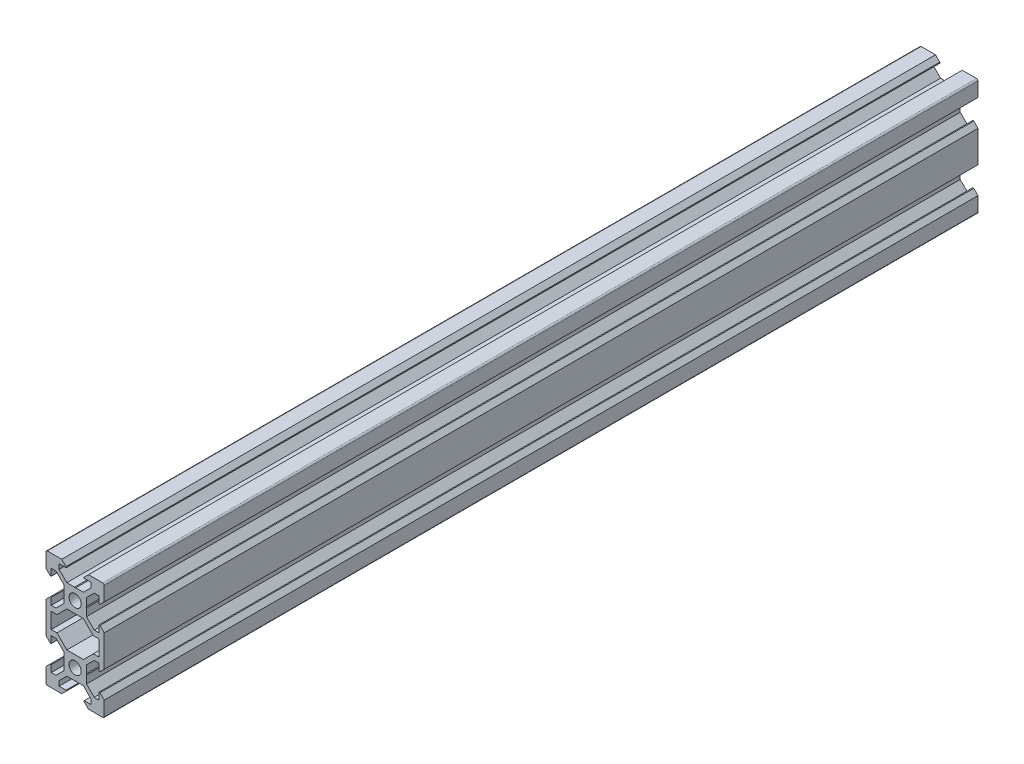
from build123d import *

# Parameters (mm, degrees)
SKETCH1_R           = 2.1
BOSS_EXTRUDE1_DEPTH = 300


with BuildPart() as part:
    # Sketch1 → Boss-Extrude1 (new body)
    with BuildSketch(Plane.XY):
        with BuildLine():
            Line((4.58, -20), (9.5, -20))
            ThreePointArc((9.5, -20), (9.853553391, -19.853553391), (10, -19.5))
            Line((10, -19.5), (10, -14.58))
            Line((10, -14.58), (8.545, -13.125))
            Line((8.545, -13.125), (8.2, -13.125))
            Line((8.2, -13.125), (8.2, -15.5))
            Line((8.2, -15.5), (6.560660172, -15.5))
            Line((6.560660172, -15.5), (3.9, -12.839339828))
            Line((3.9, -12.839339828), (3.9, -10.21))
            Line((3.9, -10.21), (3.69, -10))
            Line((3.69, -10), (3.9, -9.79))
            Line((3.9, -9.79), (3.9, -7.160660172))
            Line((3.9, -7.160660172), (6.560660172, -4.5))
            Line((6.560660172, -4.5), (8.2, -4.5))
            Line((8.2, -4.5), (8.2, -6.875))
            Line((8.2, -6.875), (8.545, -6.875))
            Line((8.545, -6.875), (10, -5.42))
            Line((10, -5.42), (10, 5.42))
            Line((10, 5.42), (8.545, 6.875))
            Line((8.545, 6.875), (8.2, 6.875))
            Line((8.2, 6.875), (8.2, 4.5))
            Line((8.2, 4.5), (6.560660172, 4.5))
            Line((6.560660172, 4.5), (3.9, 7.160660172))
            Line((3.9, 7.160660172), (3.9, 9.79))
            Line((3.9, 9.79), (3.69, 10))
            Line((3.69, 10), (3.9, 10.21))
            Line((3.9, 10.21), (3.9, 12.839339828))
            Line((3.9, 12.839339828), (6.560660172, 15.5))
            Line((6.560660172, 15.5), (8.2, 15.5))
            Line((8.2, 15.5), (8.2, 13.125))
            Line((8.2, 13.125), (8.545, 13.125))
            Line((8.545, 13.125), (10, 14.58))
            Line((10, 14.58), (10, 19.5))
            ThreePointArc((10, 19.5), (9.853553391, 19.853553391), (9.5, 20))
            Line((9.5, 20), (4.58, 20))
            Line((4.58, 20), (3.125, 18.545))
            Line((3.125, 18.545), (3.125, 18.2))
            Line((3.125, 18.2), (5.5, 18.2))
            Line((5.5, 18.2), (5.5, 16.560660172))
            Line((5.5, 16.560660172), (2.839339828, 13.9))
            Line((2.839339828, 13.9), (0.21, 13.9))
            Line((0.21, 13.9), (0, 13.69))
            Line((0, 13.69), (-0.21, 13.9))
            Line((-0.21, 13.9), (-2.839339828, 13.9))
            Line((-2.839339828, 13.9), (-5.5, 16.560660172))
            Line((-5.5, 16.560660172), (-5.5, 18.2))
            Line((-5.5, 18.2), (-3.125, 18.2))
            Line((-3.125, 18.2), (-3.125, 18.545))
            Line((-3.125, 18.545), (-4.58, 20))
            Line((-4.58, 20), (-9.5, 20))
            ThreePointArc((-9.5, 20), (-9.853553391, 19.853553391), (-10, 19.5))
            Line((-10, 19.5), (-10, 14.58))
            Line((-10, 14.58), (-8.545, 13.125))
            Line((-8.545, 13.125), (-8.2, 13.125))
            Line((-8.2, 13.125), (-8.2, 15.5))
            Line((-8.2, 15.5), (-6.560660172, 15.5))
            Line((-6.560660172, 15.5), (-3.9, 12.839339828))
            Line((-3.9, 12.839339828), (-3.9, 10.21))
            Line((-3.9, 10.21), (-3.69, 10))
            Line((-3.69, 10), (-3.9, 9.79))
            Line((-3.9, 9.79), (-3.9, 7.160660172))
            Line((-3.9, 7.160660172), (-6.560660172, 4.5))
            Line((-6.560660172, 4.5), (-8.2, 4.5))
            Line((-8.2, 4.5), (-8.2, 6.875))
            Line((-8.2, 6.875), (-8.545, 6.875))
            Line((-8.545, 6.875), (-10, 5.42))
            Line((-10, 5.42), (-10, -5.42))
            Line((-10, -5.42), (-8.545, -6.875))
            Line((-8.545, -6.875), (-8.2, -6.875))
            Line((-8.2, -6.875), (-8.2, -4.5))
            Line((-8.2, -4.5), (-6.560660172, -4.5))
            Line((-6.560660172, -4.5), (-3.9, -7.160660172))
            Line((-3.9, -7.160660172), (-3.9, -9.79))
            Line((-3.9, -9.79), (-3.69, -10))
            Line((-3.69, -10), (-3.9, -10.21))
            Line((-3.9, -10.21), (-3.9, -12.839339828))
            Line((-3.9, -12.839339828), (-6.560660172, -15.5))
            Line((-6.560660172, -15.5), (-8.2, -15.5))
            Line((-8.2, -15.5), (-8.2, -13.125))
            Line((-8.2, -13.125), (-8.545, -13.125))
            Line((-8.545, -13.125), (-10, -14.58))
            Line((-10, -14.58), (-10, -19.5))
            ThreePointArc((-10, -19.5), (-9.853553391, -19.853553391), (-9.5, -20))
            Line((-9.5, -20), (-4.58, -20))
            Line((-4.58, -20), (-3.125, -18.545))
            Line((-3.125, -18.545), (-3.125, -18.2))
            Line((-3.125, -18.2), (-5.5, -18.2))
            Line((-5.5, -18.2), (-5.5, -16.560660172))
            Line((-5.5, -16.560660172), (-2.839339828, -13.9))
            Line((-2.839339828, -13.9), (-0.21, -13.9))
            Line((-0.21, -13.9), (0, -13.69))
            Line((0, -13.69), (0.21, -13.9))
            Line((0.21, -13.9), (2.839339828, -13.9))
            Line((2.839339828, -13.9), (5.5, -16.560660172))
            Line((5.5, -16.560660172), (5.5, -18.2))
            Line((5.5, -18.2), (3.125, -18.2))
            Line((3.125, -18.2), (3.125, -18.545))
            Line((3.125, -18.545), (4.58, -20))
        make_face()
        with Locations((0, -10)):
            Circle(SKETCH1_R, mode=Mode.SUBTRACT)
        Polygon((-6.239339828, -2.7), (-8.2, -2.7), (-8.2, 2.7), (-6.239339828, 2.7), (-2.839339828, 6.1), (2.839339828, 6.1), (6.239339828, 2.7), (8.2, 2.7), (8.2, -2.7), (6.239339828, -2.7), (2.839339828, -6.1), (-2.839339828, -6.1), align=None, mode=Mode.SUBTRACT)
        with Locations((0, 10)):
            Circle(SKETCH1_R, mode=Mode.SUBTRACT)
    extrude(amount=BOSS_EXTRUDE1_DEPTH)


solid = part.part
